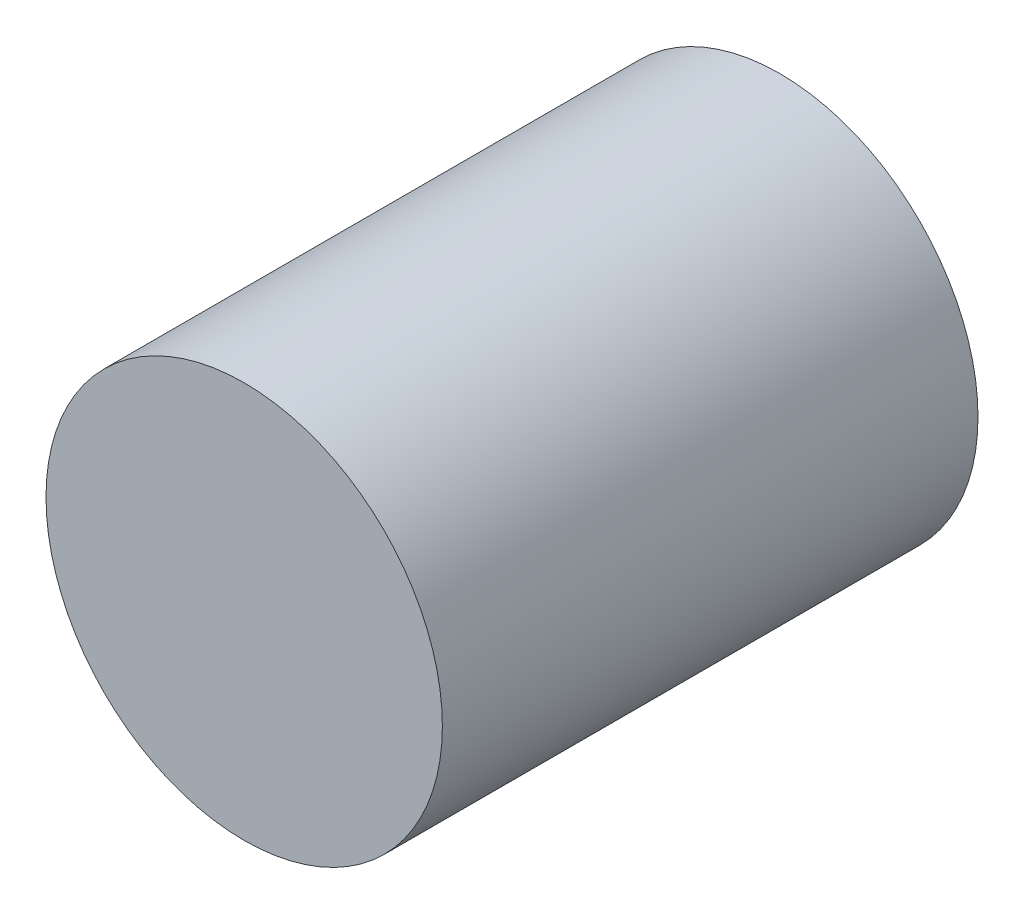
from build123d import *

# Parameters (mm, degrees)
SKETCH2_R           = 4.699
BOSS_EXTRUDE1_DEPTH = 12.7
SCALE1_SCALE        = 0.65


with BuildPart() as part:
    # Sketch2 → Boss-Extrude1 (new body)
    with BuildSketch(Plane.XY):
        Circle(SKETCH2_R)
    extrude(amount=BOSS_EXTRUDE1_DEPTH)


with BuildPart() as part_1:
    # Scale1: scaled about (0, 0, 6.35)
    add(part.part.scale(SCALE1_SCALE).moved(Location((0, 0, 2.2225))))


solid = part_1.part
